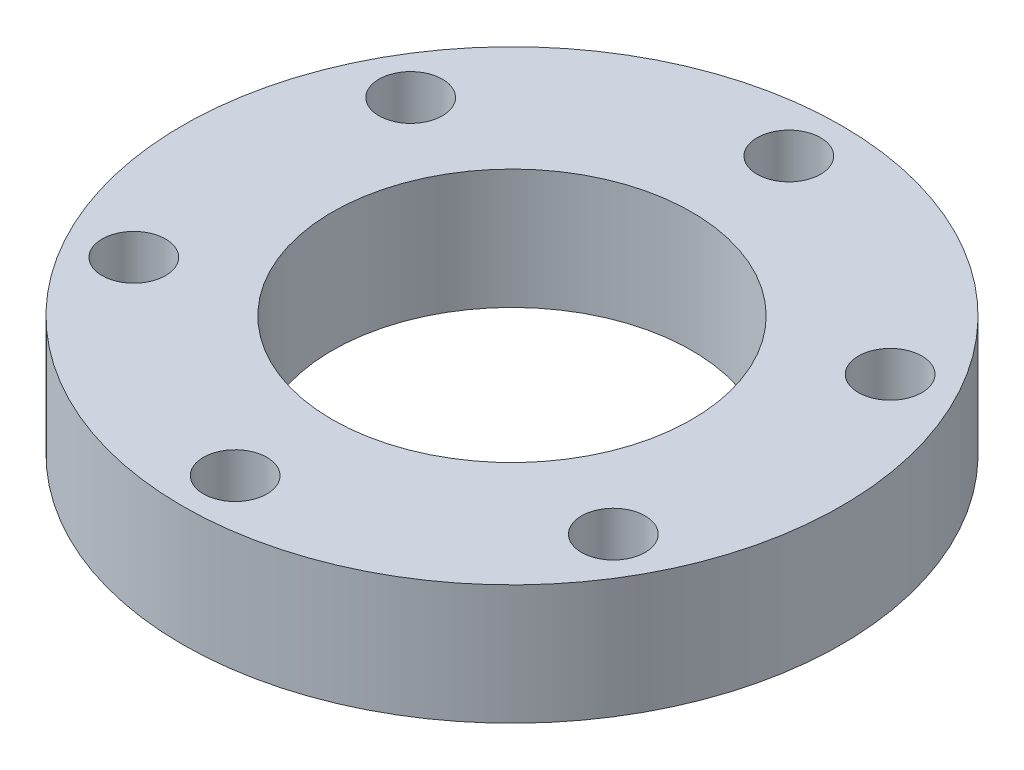
from build123d import *

# Parameters (mm, degrees)
SKETCH1_R          = 34.925
EXTRUDE1_DEPTH     = 12.7
SKETCH2_R          = 19.05
CUT_EXTRUDE1_DEPTH = 13.7
SKETCH3_R          = 3.3655
CUT_EXTRUDE2_DEPTH = 13.7
CIRPATTERN1_COUNT  = 6


with BuildPart() as part:
    # Sketch1 → Extrude1 (new body)
    with BuildSketch(Plane(origin=(0, 0, 0), x_dir=(1, 0, 0), z_dir=(0, 1, 0))):
        Circle(SKETCH1_R)
    extrude(amount=EXTRUDE1_DEPTH)

    # Sketch2 → Cut-Extrude1 (cut, through all)
    with BuildSketch(Plane(origin=(0, 0, 0), x_dir=(1, 0, 0), z_dir=(0, 1, 0))):
        Circle(SKETCH2_R)
    extrude(amount=CUT_EXTRUDE1_DEPTH, mode=Mode.SUBTRACT)

    # Sketch3 → Cut-Extrude2 (cut, through all)
    with BuildSketch(Plane(origin=(0, 0, 0), x_dir=(1, 0, 0), z_dir=(0, 1, 0))):
        with Locations((0, 29.337)):
            Circle(SKETCH3_R)
    cut_extrude2 = extrude(amount=CUT_EXTRUDE2_DEPTH, mode=Mode.SUBTRACT)

    # CirPattern1: Cut-Extrude2 ×6 about axis
    cirpattern1_axis = Axis((0, 0, 0), (0, 1, 0))
    for i in range(1, CIRPATTERN1_COUNT):
        add(cut_extrude2.rotate(cirpattern1_axis, i * 360 / CIRPATTERN1_COUNT), mode=Mode.SUBTRACT)


solid = part.part
